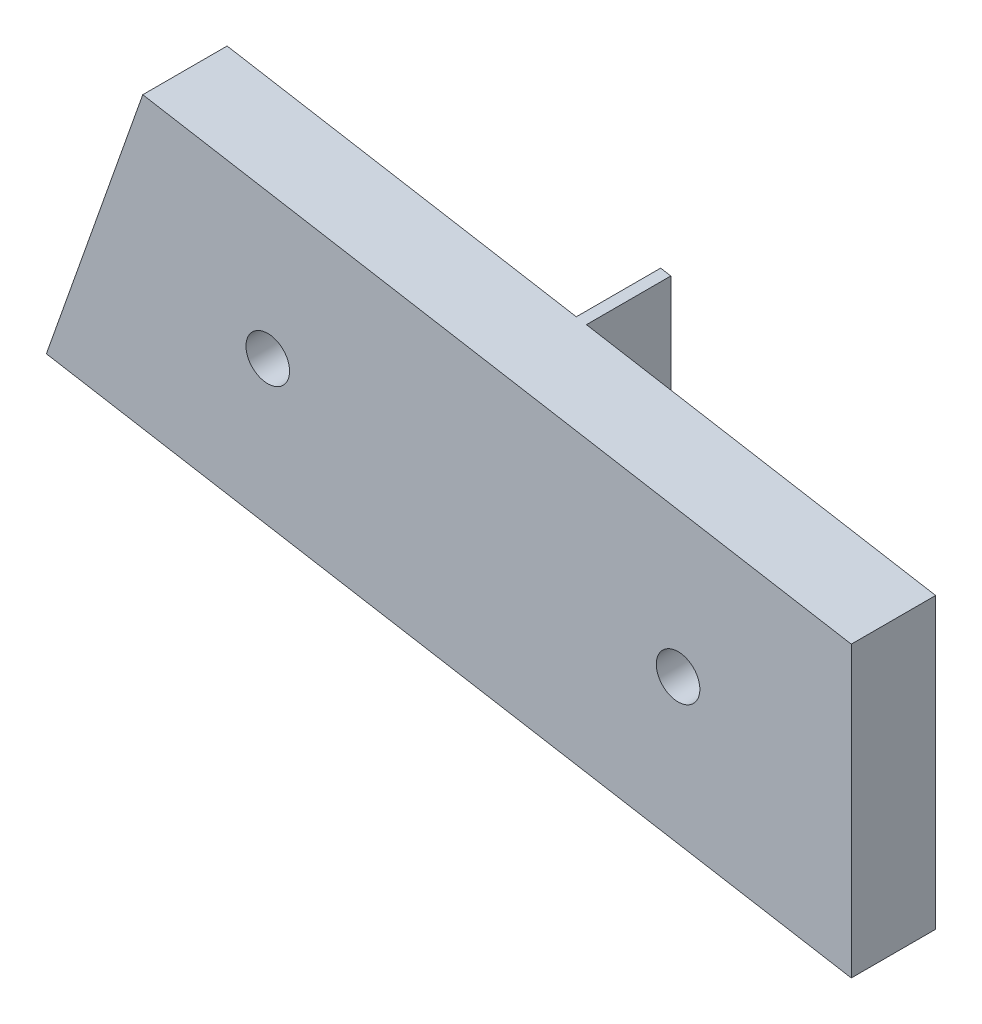
from build123d import *

# Parameters (mm, degrees)
EXTRUDE_1_DEPTH     = 6
EXTRUDE_2_DEPTH     = 6
SKETCH_3_R          = 1.55
CUT_EXTRUDE_1_DEPTH = 6


with BuildPart() as part:
    # Эскиз1 → Бобышка-Вытянуть1 (new body)
    with BuildSketch(Plane.XY):
        Polygon((-114.323496858, 125.813994573), (-171.575189585, 135.638663443), (-164.719145048, 155.026651824), (-114.323496858, 146.378513535), align=None)
    extrude(amount=EXTRUDE_1_DEPTH)

    # Эскиз2 → Бобышка-Вытянуть2 (add)
    with BuildSketch(Plane(origin=(0, 0, 0), x_dir=(-1, 0, 0), z_dir=(0, 0, -1))):
        Polygon((146.738238306, 131.376521829), (139.160448137, 130.076136187), (139.160448137, 150.64065515), (139.882193768, 150.76451021), align=None)
    extrude(amount=EXTRUDE_2_DEPTH)

    # Эскиз3 → Вырез-Вытянуть1 (cut)
    with BuildSketch(Plane(origin=(0, 0, 0), x_dir=(-1, 0, 0), z_dir=(0, 0, -1))):
        with Locations((126.643413167, 138.210411601)):
            Circle(SKETCH_3_R)
        with Locations((155.827251007, 143.218500087)):
            Circle(SKETCH_3_R)
    extrude(amount=-CUT_EXTRUDE_1_DEPTH, mode=Mode.SUBTRACT)


solid = part.part
